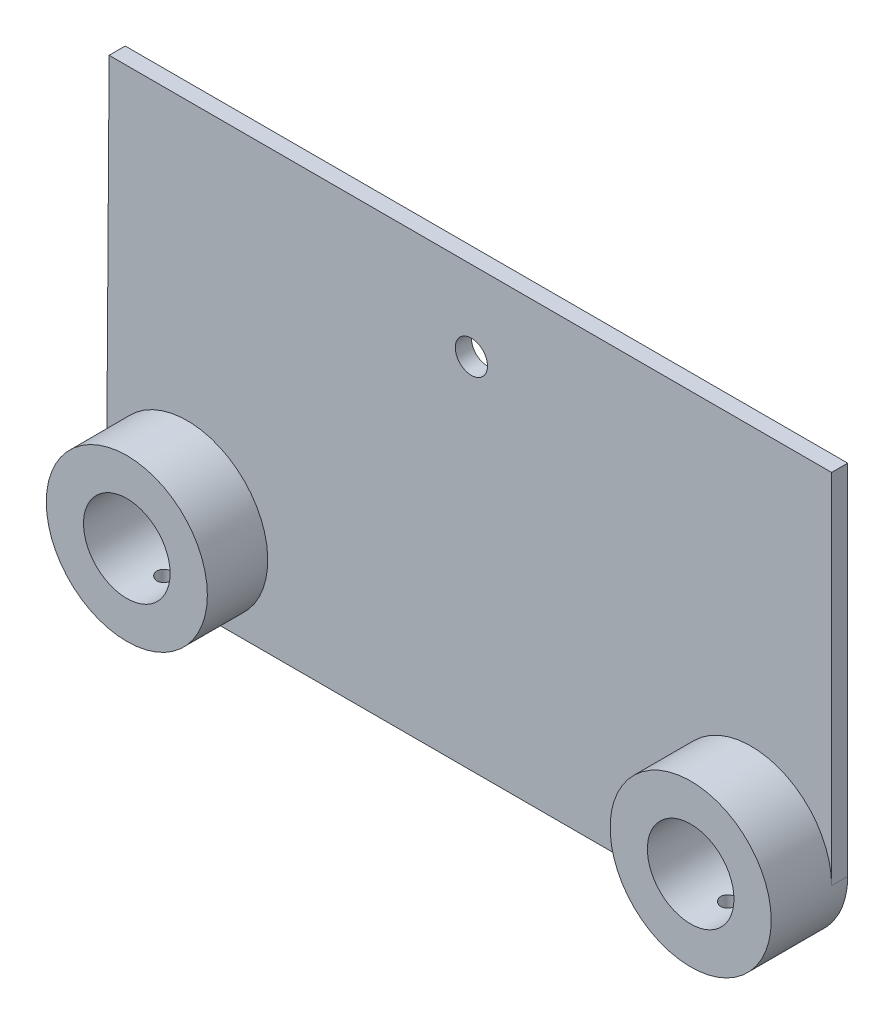
from build123d import *

# Parameters (mm, degrees)
SKETCH1_R           = 10.75
BOSS_EXTRUDE1_DEPTH = 4
SKETCH2_R           = 4
CUT_EXTRUDE1_DEPTH  = 10
SKETCH3_R           = 20
SKETCH3_R_2         = 10.75
BOSS_EXTRUDE2_DEPTH = 19
SKETCH4_R           = 2
CUT_EXTRUDE2_DEPTH  = 20


with BuildPart() as part:
    # Sketch1 → Boss-Extrude1 (new body)
    with BuildSketch(Plane.XY):
        with BuildLine():
            Line((-70, -20), (70, -20))
            ThreePointArc((70, -20), (84.142136, -14.142136), (90, 0))
            Line((90, 0), (90, 88.85))
            Line((90, 88.85), (-89.389486, 88.85))
            Line((-89.389486, 88.85), (-90, 0))
            ThreePointArc((-90, 0), (-84.142136, -14.142136), (-70, -20))
        make_face()
        with Locations((70, 0)):
            Circle(SKETCH1_R, mode=Mode.SUBTRACT)
        with Locations((-70, 0)):
            Circle(SKETCH1_R, mode=Mode.SUBTRACT)
    extrude(amount=BOSS_EXTRUDE1_DEPTH)

    # Sketch2 → Cut-Extrude1 (cut)
    with BuildSketch(Plane.XY):
        with Locations((0.554741, 69)):
            Circle(SKETCH2_R)
    extrude(amount=CUT_EXTRUDE1_DEPTH, mode=Mode.SUBTRACT)

    # Sketch3 → Boss-Extrude2 (add)
    with BuildSketch(Plane.XY):
        with Locations((-70, 0)):
            Circle(SKETCH3_R)
        with Locations((-70, 0)):
            Circle(SKETCH3_R_2, mode=Mode.SUBTRACT)
        with Locations((70, 0)):
            Circle(SKETCH3_R)
        with Locations((70, 0)):
            Circle(SKETCH3_R_2, mode=Mode.SUBTRACT)
    extrude(amount=BOSS_EXTRUDE2_DEPTH)

    # Sketch4 → Cut-Extrude2 (cut)
    with BuildSketch(Plane(origin=(0, 0, 0), x_dir=(1, 0, 0), z_dir=(0, 1, 0))):
        with Locations((-70, -9.5)):
            Circle(SKETCH4_R)
        with Locations((70, -9.5)):
            Circle(SKETCH4_R)
    extrude(amount=-CUT_EXTRUDE2_DEPTH, mode=Mode.SUBTRACT)


solid = part.part
